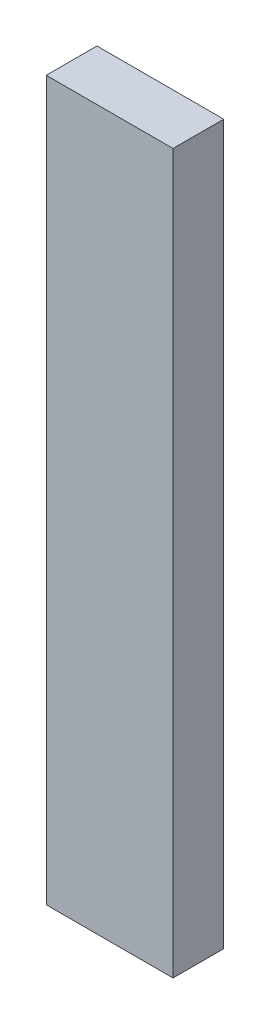
from build123d import *

# Parameters (mm, degrees)
ESQUISSE1_W        = 15
ESQUISSE1_H        = 85
BOSS_EXTRU_1_DEPTH = 6


with BuildPart() as part:
    # Esquisse1 → Boss.-Extru.1 (new body)
    with BuildSketch(Plane.XY):
        Rectangle(ESQUISSE1_W, ESQUISSE1_H)
    extrude(amount=BOSS_EXTRU_1_DEPTH)


solid = part.part
